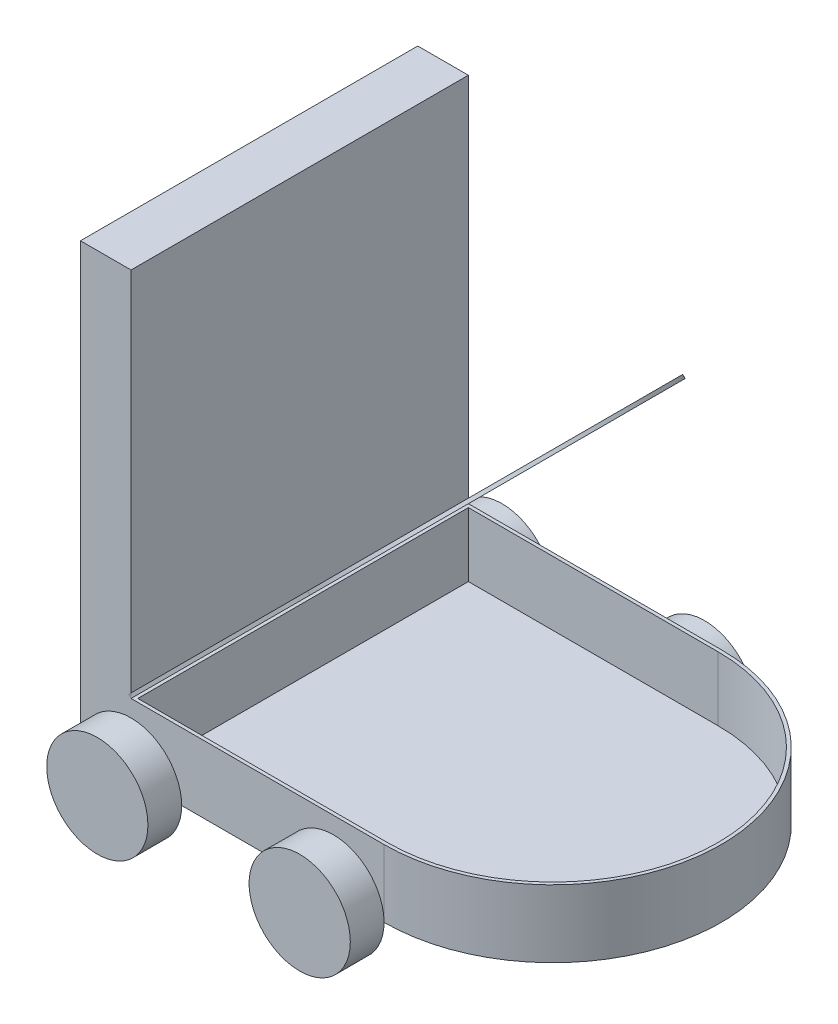
from build123d import *

# Parameters (mm, degrees)
HORIZONTAL_BODY_DEPTH    = 20
SHELL_OF_BASE_T          = -1
SKETCH3_W                = 15
SKETCH3_H                = 100
VERTICAL_BODY_DEPTH      = 130
SKETCH4_R                = 15
WHEEL_DEPTH              = 10
WHEEL_PATTERN_COUNT      = 2
WHEEL_PATTERN_PITCH      = 60
WHEEL_PATTERN_COUNT_DIR2 = 2
WHEEL_PATTERN_PITCH_DIR2 = 110
SKETCH6_W                = 40
SKETCH6_H                = 40
LID_DEPTH                = 1


with BuildPart() as part:
    # Sketch1 → Horizontal body (new body)
    with BuildSketch(Plane(origin=(0, 15, 0), x_dir=(1, 0, 0), z_dir=(0, 1, 0))):
        with BuildLine():
            Line((15, 0), (15, 100))
            Line((15, 100), (90, 100))
            ThreePointArc((90, 100), (140, 50), (90, 0))
            Line((90, 0), (15, 0))
        make_face()
    extrude(amount=HORIZONTAL_BODY_DEPTH)

    # Shell of base
    shell_of_base_openings = [part.faces().sort_by_distance(p)[0] for p in [
        (72.679896235, 35, -50),
    ]]
    offset(amount=SHELL_OF_BASE_T, openings=shell_of_base_openings, kind=Kind.INTERSECTION)

    # Sketch3 → Vertical body (add)
    with BuildSketch(Plane(origin=(0, 15, 0), x_dir=(1, 0, 0), z_dir=(0, 1, 0))):
        with Locations((7.5, 50)):
            Rectangle(SKETCH3_W, SKETCH3_H)
    extrude(amount=VERTICAL_BODY_DEPTH)

    # Sketch4 → Wheel (add)
    with BuildSketch(Plane.XY):
        with Locations((15, 15)):
            Circle(SKETCH4_R)
    wheel = extrude(amount=WHEEL_DEPTH)

    # Wheel pattern: Wheel 2 × 2
    with Locations(*[(i * WHEEL_PATTERN_PITCH, 0, -j * WHEEL_PATTERN_PITCH_DIR2) for i in range(WHEEL_PATTERN_COUNT) for j in range(WHEEL_PATTERN_COUNT_DIR2) if (i, j) != (0, 0)]):
        add(wheel)


with BuildPart() as body_2:
    # Sketch6 → Lid (new body)
    with BuildSketch(Plane(origin=(-10, 10, 0), x_dir=(0.707106781, 0.707106781, 0), z_dir=(-0.707106781, 0.707106781, 0))):
        with BuildLine():
            Line((110.355339059, 100), (35.355339059, 100))
            Line((35.355339059, 100), (35.355339059, 0))
            Line((35.355339059, 0), (110.355339059, 0))
            ThreePointArc((110.355339059, 0), (160.355339059, 50), (110.355339059, 100))
        make_face()
        Polygon((65.355339059, 44.641016151), (45.355339059, 10), (85.355339059, 10), align=None, mode=Mode.SUBTRACT)
        with Locations((65.355339059, 70)):
            Rectangle(SKETCH6_W, SKETCH6_H, mode=Mode.SUBTRACT)
        Polygon((123.887034548, 25.729490169), (141.520592117, 50), (123.887034548, 74.270509831), (95.355339059, 65), (95.355339059, 35), align=None, mode=Mode.SUBTRACT)
    extrude(amount=LID_DEPTH)


solid = Compound([part.part, body_2.part])
